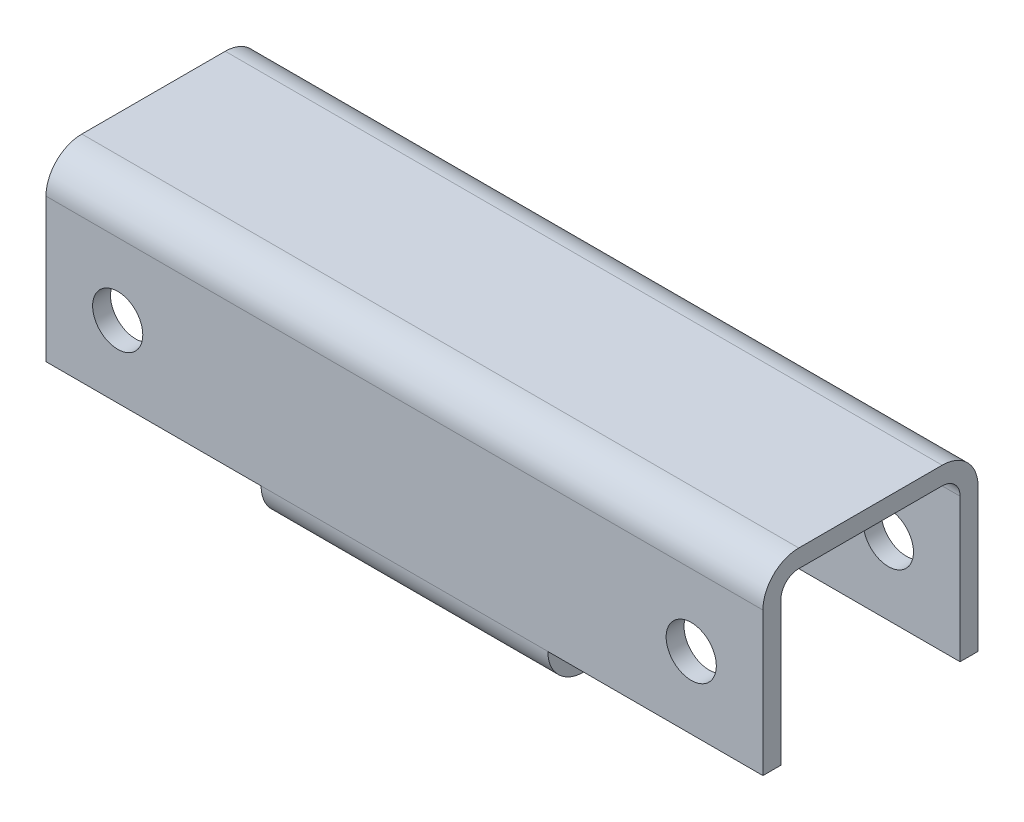
from build123d import *

# Parameters (mm, degrees)
EL_MENT_M_CANO_SOUD_1_DEPTH     = 200
ESQUISSE2_W                     = 60
ESQUISSE2_H                     = 10
ENL_V_MAT_EXTRU_1_DEPTH         = 60
DIAM_TRE_DU_PER_AGE_14_0_14_1_D = 14


with BuildPart() as part:
    # Sketch1 → Elément mécano-soudé1 (new body)
    with BuildSketch(Plane.YZ.offset(-100)):
        with BuildLine():
            Line((-20, -30), (20, -30))
            ThreePointArc((20, -30), (27.071067812, -27.071067812), (30, -20))
            Line((30, -20), (30, 20))
            ThreePointArc((30, 20), (27.071067812, 27.071067812), (20, 30))
            Line((20, 30), (-20, 30))
            ThreePointArc((-20, 30), (-27.071067812, 27.071067812), (-30, 20))
            Line((-30, 20), (-30, -20))
            ThreePointArc((-30, -20), (-27.071067812, -27.071067812), (-20, -30))
        make_face()
        with BuildLine():
            Line((-20, -25), (20, -25))
            ThreePointArc((20, -25), (23.535533906, -23.535533906), (25, -20))
            Line((25, -20), (25, 20))
            ThreePointArc((25, 20), (23.535533906, 23.535533906), (20, 25))
            Line((20, 25), (-20, 25))
            ThreePointArc((-20, 25), (-23.535533906, 23.535533906), (-25, 20))
            Line((-25, 20), (-25, -20))
            ThreePointArc((-25, -20), (-23.535533906, -23.535533906), (-20, -25))
        make_face(mode=Mode.SUBTRACT)
    extrude(amount=EL_MENT_M_CANO_SOUD_1_DEPTH)

    # Esquisse2 → Enlèv. mat.-Extru.1 (cut)
    with BuildSketch(Plane(origin=(-100, 0, 0), x_dir=(0, 0, -1), z_dir=(1, 0, 0))):
        with Locations((0, -25)):
            Rectangle(ESQUISSE2_W, ESQUISSE2_H)
    enl_v_mat_extru_1 = extrude(amount=ENL_V_MAT_EXTRU_1_DEPTH, mode=Mode.SUBTRACT)

    # Diamètre du perçage Ø14.0 (14)1 (through all)
    with Locations(Plane.XY.offset(30)):
        with Locations((-80, 0), (80, 0)):
            Hole(DIAM_TRE_DU_PER_AGE_14_0_14_1_D / 2)

    # Symétrie1: Enlèv. mat.-Extru.1 across plane
    add(enl_v_mat_extru_1.mirror(Plane(origin=(0, 0, 0), x_dir=(0, 0, 1), z_dir=(1, 0, 0))), mode=Mode.SUBTRACT)


solid = part.part
